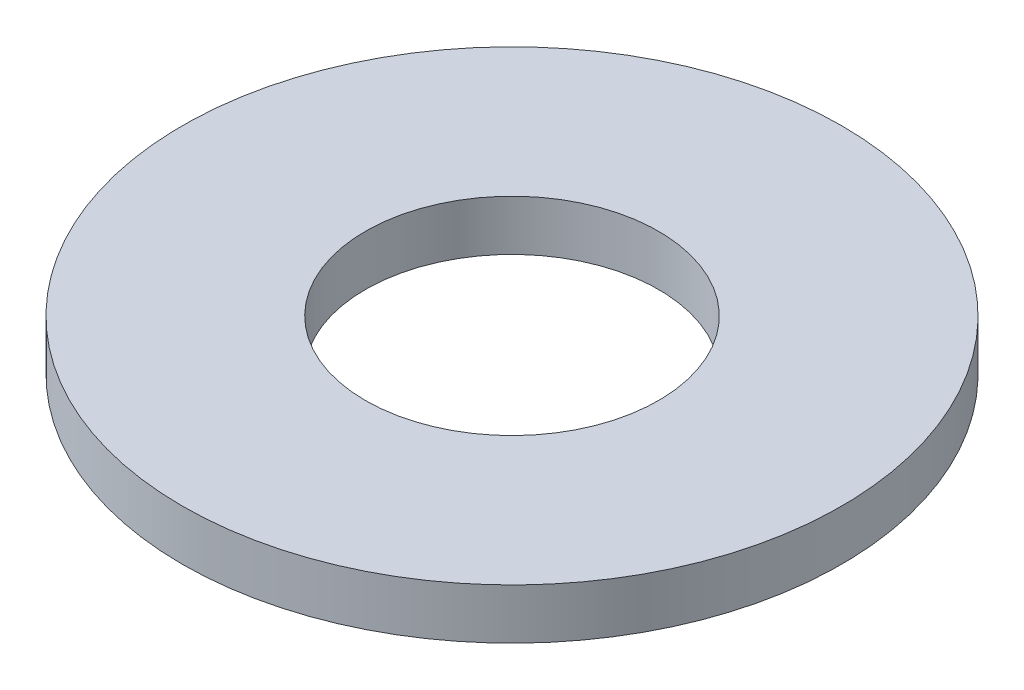
from build123d import *

# Parameters (mm, degrees)
SKETCH1_R           = 7.1374
BOSS_EXTRUDE1_DEPTH = 1.0922
SKETCH5_R           = 3.175
CUT_EXTRUDE1_DEPTH  = 2.0922


with BuildPart() as part:
    # Sketch1 → Boss-Extrude1 (new body)
    with BuildSketch(Plane(origin=(0, 0, 0), x_dir=(1, 0, 0), z_dir=(0, 1, 0))):
        Circle(SKETCH1_R)
    extrude(amount=BOSS_EXTRUDE1_DEPTH)

    # Sketch5 → Cut-Extrude1 (cut, through all)
    with BuildSketch(Plane(origin=(0, 1.0922, 0), x_dir=(-1, 0, 0), z_dir=(0, 1, 0))):
        Circle(SKETCH5_R)
    extrude(amount=-CUT_EXTRUDE1_DEPTH, mode=Mode.SUBTRACT)


solid = part.part
